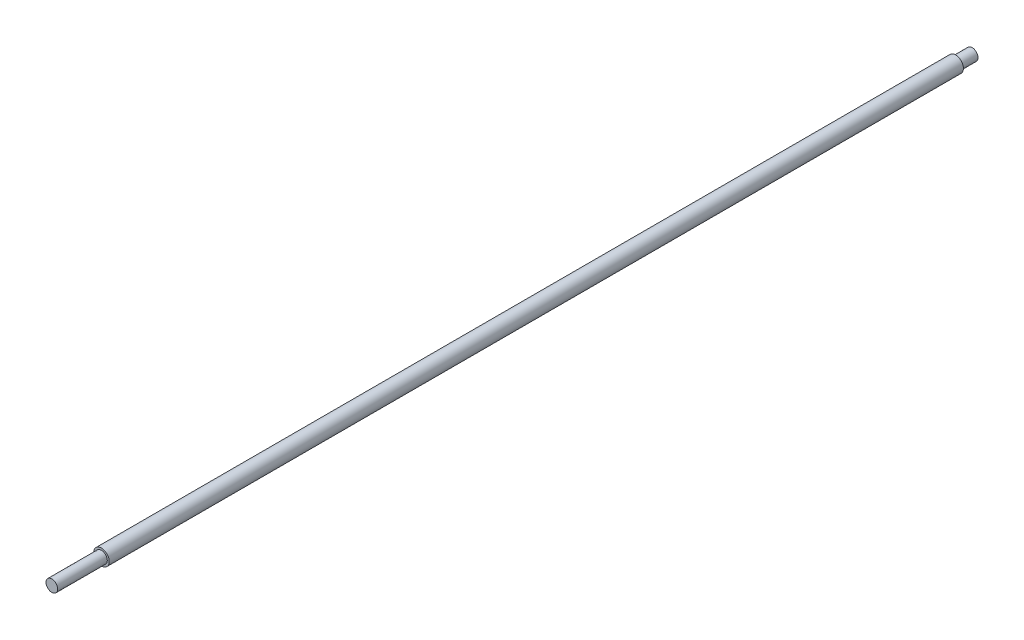
from build123d import *

# Parameters (mm, degrees)
SKETCH1_R          = 8
EXTRUDE1_DEPTH     = 946
SKETCH3_R          = 8
SKETCH3_R_2        = 6
CUT_EXTRUDE1_DEPTH = 54
SKETCH4_R          = 8
SKETCH4_R_2        = 6
CUT_EXTRUDE2_DEPTH = 20
SKETCH5_R          = 8
SKETCH5_R_2        = 6
EXTRUDE2_DEPTH     = 3
SKETCH6_R          = 8
SKETCH6_R_2        = 6
EXTRUDE3_DEPTH     = 3


with BuildPart() as part:
    # Sketch1 → Extrude1 (new body)
    with BuildSketch(Plane.XY):
        Circle(SKETCH1_R)
    extrude(amount=EXTRUDE1_DEPTH)

    # Sketch3 → Cut-Extrude1 (cut)
    with BuildSketch(Plane.XY.offset(946)):
        Circle(SKETCH3_R)
        Circle(SKETCH3_R_2, mode=Mode.SUBTRACT)
    extrude(amount=-CUT_EXTRUDE1_DEPTH, mode=Mode.SUBTRACT)

    # Sketch4 → Cut-Extrude2 (cut)
    with BuildSketch(Plane(origin=(0, 0, 0), x_dir=(-1, 0, 0), z_dir=(0, 0, -1))):
        Circle(SKETCH4_R)
        Circle(SKETCH4_R_2, mode=Mode.SUBTRACT)
    extrude(amount=-CUT_EXTRUDE2_DEPTH, mode=Mode.SUBTRACT)

    # Sketch5 → Extrude2 (add)
    with BuildSketch(Plane(origin=(0, 0, 20), x_dir=(-1, 0, 0), z_dir=(0, 0, -1))):
        Circle(SKETCH5_R)
        Circle(SKETCH5_R_2, mode=Mode.SUBTRACT)
    extrude(amount=EXTRUDE2_DEPTH)

    # Sketch6 → Extrude3 (add)
    with BuildSketch(Plane.XY.offset(892)):
        Circle(SKETCH6_R)
        Circle(SKETCH6_R_2, mode=Mode.SUBTRACT)
    extrude(amount=EXTRUDE3_DEPTH)


solid = part.part
